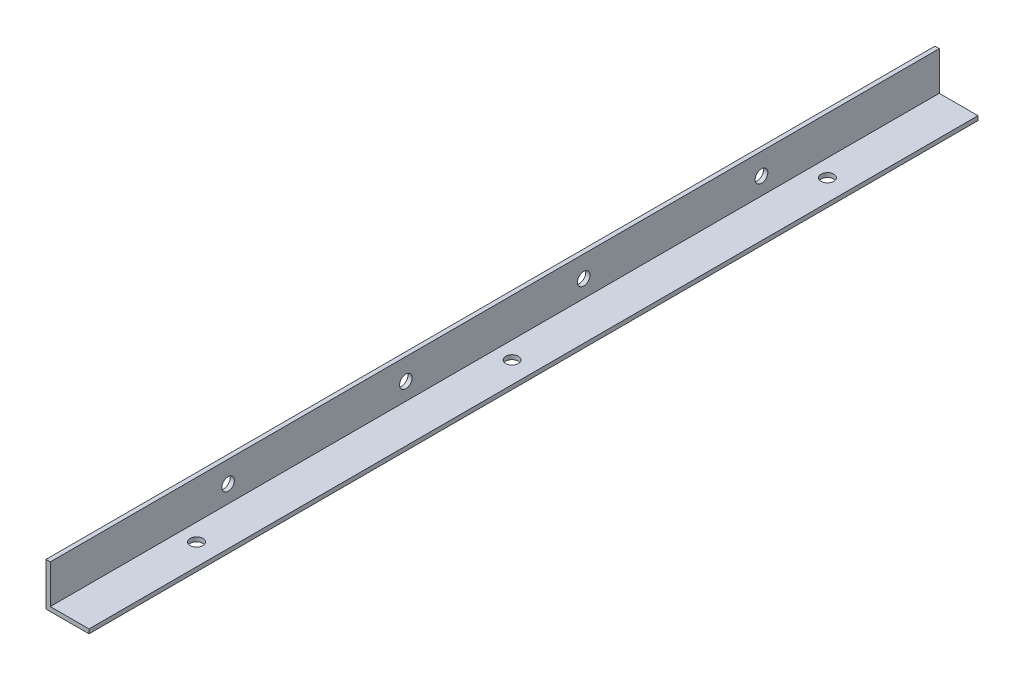
from build123d import *

# Parameters (mm, degrees)
EXTRUDE_1_DEPTH     = 310
SKETCH_2_R          = 2.2
CUT_EXTRUDE_1_DEPTH = 310
SKETCH_3_R          = 2.2
CUT_EXTRUDE_2_DEPTH = 160


with BuildPart() as part:
    # ｽｹｯﾁ1 → ﾎﾞｽ - 押し出し1 (new body)
    with BuildSketch(Plane.XY):
        Polygon((0, 0), (0, -15), (15, -15), (15, -13.5), (1.5, -13.5), (1.5, 0), align=None)
    extrude(amount=EXTRUDE_1_DEPTH)

    # ｽｹｯﾁ2 → ｶｯﾄ - 押し出し1 (cut)
    with BuildSketch(Plane.ZY):
        with Locations((248, -7.5)):
            Circle(SKETCH_2_R)
        with Locations((186, -7.5)):
            Circle(SKETCH_2_R)
        with Locations((124, -7.5)):
            Circle(SKETCH_2_R)
        with Locations((62, -7.5)):
            Circle(SKETCH_2_R)
    extrude(amount=-CUT_EXTRUDE_1_DEPTH, mode=Mode.SUBTRACT)

    # ｽｹｯﾁ3 → ｶｯﾄ - 押し出し2 (cut)
    with BuildSketch(Plane(origin=(0, -15, 0), x_dir=(-1, 0, 0), z_dir=(0, -1, 0))):
        with Locations((-7.5, -265)):
            Circle(SKETCH_3_R)
        with Locations((-7.5, -155)):
            Circle(SKETCH_3_R)
        with Locations((-7.5, -45)):
            Circle(SKETCH_3_R)
    extrude(amount=-CUT_EXTRUDE_2_DEPTH, mode=Mode.SUBTRACT)


solid = part.part
